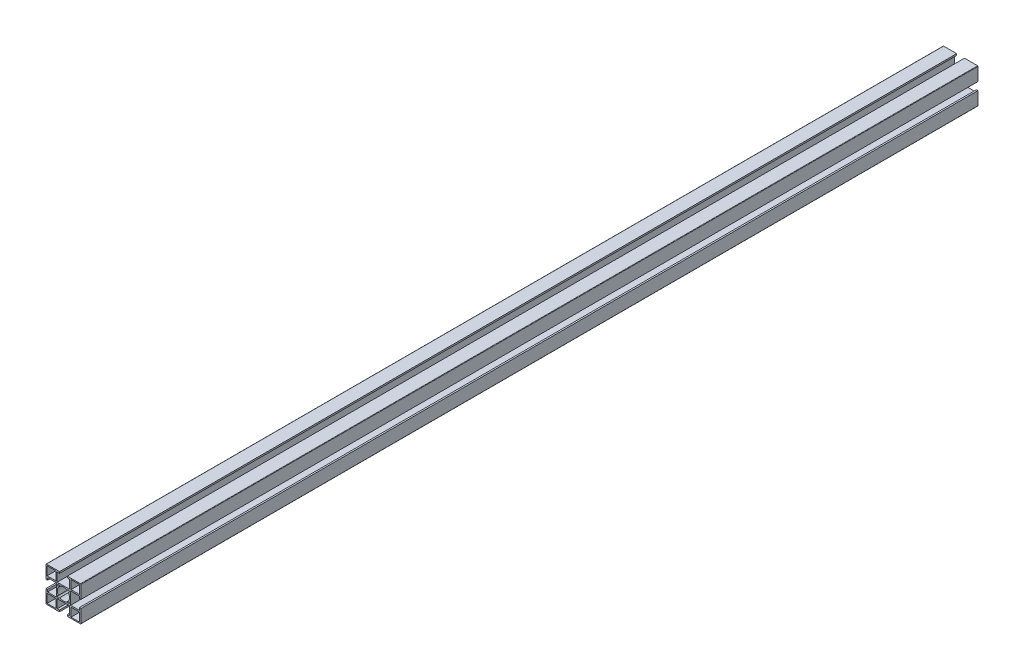
from build123d import *

# Parameters (mm, degrees)
SKETCH1_W                 = 10
SKETCH1_H                 = 10
F_40_X_40A_X_R0_5_1_DEPTH = 1030
SKETCH_2_R                = 2.5
CUT_EXTRUDE_1_DEPTH       = 1031.580050263


with BuildPart() as part:
    # Sketch1 → 铝型材 40 X 40A X R0.5(1) (new body)
    with BuildSketch(Plane.YX):
        with BuildLine():
            Line((-19.5, 20), (-4.5, 20))
            Line((-4.5, 20), (-4.5, 18.2))
            Line((-4.5, 18.2), (-7.1, 18.2))
            Line((-7.1, 18.2), (-7.1, 8.2))
            Line((-7.1, 8.2), (7.1, 8.2))
            Line((7.1, 8.2), (7.1, 18.2))
            Line((7.1, 18.2), (4.5, 18.2))
            Line((4.5, 18.2), (4.5, 20))
            Line((4.5, 20), (19.5, 20))
            ThreePointArc((19.5, 20), (19.853553391, 19.853553391), (20, 19.5))
            Line((20, 19.5), (20, 4.5))
            Line((20, 4.5), (18.2, 4.5))
            Line((18.2, 4.5), (18.2, 7.1))
            Line((18.2, 7.1), (8.2, 7.1))
            Line((8.2, 7.1), (8.2, -7.1))
            Line((8.2, -7.1), (18.2, -7.1))
            Line((18.2, -7.1), (18.2, -4.5))
            Line((18.2, -4.5), (20, -4.5))
            Line((20, -4.5), (20, -19.5))
            ThreePointArc((20, -19.5), (19.853553391, -19.853553391), (19.5, -20))
            Line((19.5, -20), (4.5, -20))
            Line((4.5, -20), (4.5, -18.2))
            Line((4.5, -18.2), (7.1, -18.2))
            Line((7.1, -18.2), (7.1, -8.2))
            Line((7.1, -8.2), (-7.1, -8.2))
            Line((-7.1, -8.2), (-7.1, -18.2))
            Line((-7.1, -18.2), (-4.5, -18.2))
            Line((-4.5, -18.2), (-4.5, -20))
            Line((-4.5, -20), (-19.5, -20))
            ThreePointArc((-19.5, -20), (-19.853553391, -19.853553391), (-20, -19.5))
            Line((-20, -19.5), (-20, -4.5))
            Line((-20, -4.5), (-18.2, -4.5))
            Line((-18.2, -4.5), (-18.2, -7.1))
            Line((-18.2, -7.1), (-8.2, -7.1))
            Line((-8.2, -7.1), (-8.2, 7.1))
            Line((-8.2, 7.1), (-18.2, 7.1))
            Line((-18.2, 7.1), (-18.2, 4.5))
            Line((-18.2, 4.5), (-20, 4.5))
            Line((-20, 4.5), (-20, 19.5))
            ThreePointArc((-20, 19.5), (-19.853553391, 19.853553391), (-19.5, 20))
        make_face()
        with BuildLine():
            Line((-4.87903679, 6.434671709), (-4.110433762, 5.66606868))
            ThreePointArc((-4.110433762, 5.66606868), (0, 7), (4.110433762, 5.66606868))
            Line((4.110433762, 5.66606868), (4.87903679, 6.434671709))
            ThreePointArc((4.87903679, 6.434671709), (6.434671709, 6.434671709), (6.434671709, 4.87903679))
            Line((6.434671709, 4.87903679), (5.66606868, 4.110433762))
            ThreePointArc((5.66606868, 4.110433762), (7, 0), (5.66606868, -4.110433762))
            Line((5.66606868, -4.110433762), (6.434671709, -4.87903679))
            ThreePointArc((6.434671709, -4.87903679), (6.434671709, -6.434671709), (4.87903679, -6.434671709))
            Line((4.87903679, -6.434671709), (4.110433762, -5.66606868))
            ThreePointArc((4.110433762, -5.66606868), (0, -7), (-4.110433762, -5.66606868))
            Line((-4.110433762, -5.66606868), (-4.87903679, -6.434671709))
            ThreePointArc((-4.87903679, -6.434671709), (-6.434671709, -6.434671709), (-6.434671709, -4.87903679))
            Line((-6.434671709, -4.87903679), (-5.66606868, -4.110433762))
            ThreePointArc((-5.66606868, -4.110433762), (-7, 0), (-5.66606868, 4.110433762))
            Line((-5.66606868, 4.110433762), (-6.434671709, 4.87903679))
            ThreePointArc((-6.434671709, 4.87903679), (-6.434671709, 6.434671709), (-4.87903679, 6.434671709))
        make_face(mode=Mode.SUBTRACT)
        with Locations((-13.7, 13.7)):
            Rectangle(SKETCH1_W, SKETCH1_H, mode=Mode.SUBTRACT)
        with Locations((13.7, 13.7)):
            Rectangle(SKETCH1_W, SKETCH1_H, mode=Mode.SUBTRACT)
        with Locations((13.7, -13.7)):
            Rectangle(SKETCH1_W, SKETCH1_H, mode=Mode.SUBTRACT)
        with Locations((-13.7, -13.7)):
            Rectangle(SKETCH1_W, SKETCH1_H, mode=Mode.SUBTRACT)
    extrude(amount=F_40_X_40A_X_R0_5_1_DEPTH)

    # 草图2 → 切除-拉伸1 (cut, through all)
    with BuildSketch(Plane(origin=(8.2, 0, 0), x_dir=(0, 0, -1), z_dir=(1, 0, 0))):
        with Locations((40, 0)):
            Circle(SKETCH_2_R)
    extrude(amount=-CUT_EXTRUDE_1_DEPTH, mode=Mode.SUBTRACT)


solid = part.part
